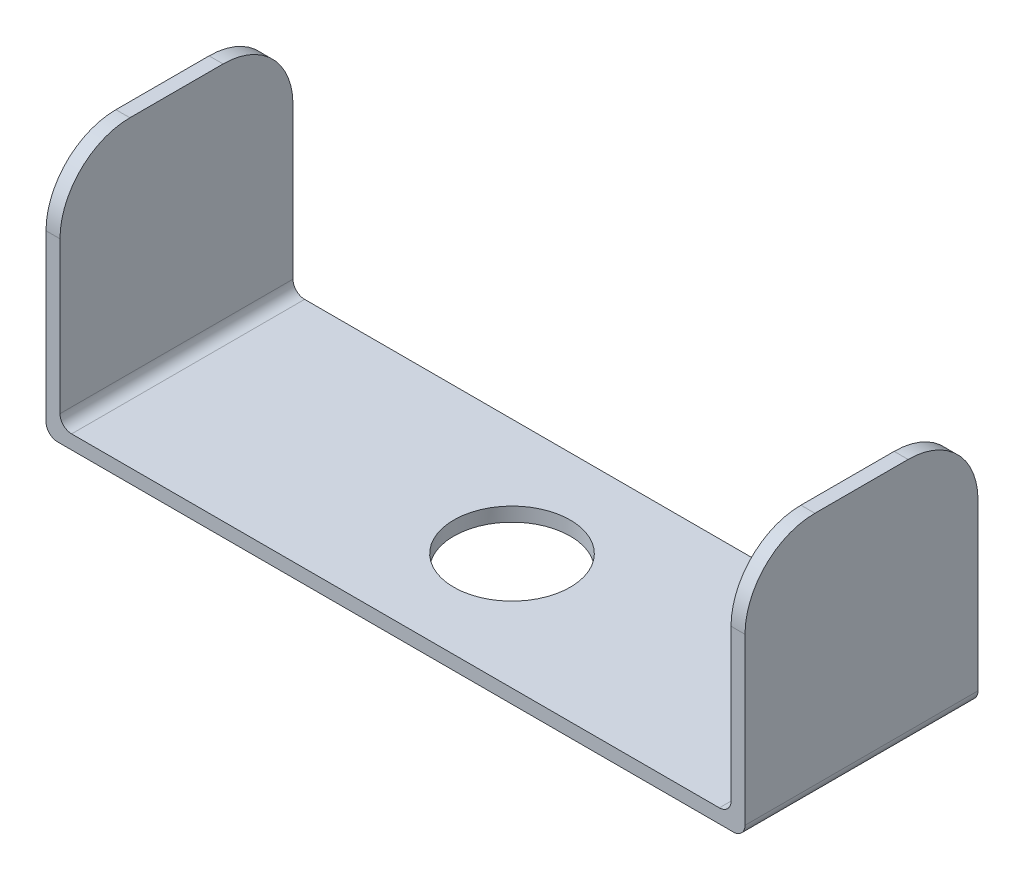
from build123d import *

# Parameters (mm, degrees)
SKETCH1_W           = 30
SKETCH1_H           = 10
BOSS_EXTRUDE1_DEPTH = 0.6
SKETCH2_W           = 0.6
SKETCH2_H           = 10
BOSS_EXTRUDE2_DEPTH = 10
FILLET1_R           = 0.5
FILLET2_R           = 3
CUT_EXTRUDE1_REACH  = 2.6
SKETCH3_R           = 2.5


with BuildPart() as part:
    # Sketch1 → Boss-Extrude1 (new body)
    with BuildSketch(Plane(origin=(0, 0, 0), x_dir=(1, 0, 0), z_dir=(0, 1, 0))):
        Rectangle(SKETCH1_W, SKETCH1_H)
    extrude(amount=BOSS_EXTRUDE1_DEPTH)

    # Sketch2 → Boss-Extrude2 (add)
    with BuildSketch(Plane(origin=(0, 0.6, 0), x_dir=(1, 0, 0), z_dir=(0, 1, 0))):
        with Locations((-14.7, 0)):
            Rectangle(SKETCH2_W, SKETCH2_H)
        with Locations((14.7, 0)):
            Rectangle(SKETCH2_W, SKETCH2_H)
    extrude(amount=BOSS_EXTRUDE2_DEPTH)

    # Fillet1
    fillet1_edges = [part.edges().sort_by_distance(p)[0] for p in [
        (-14.4, 0.6, 0),
        (14.4, 0.6, 0),
        (-15, 0, 0),
        (15, 0, 0),
    ]]
    fillet(fillet1_edges, radius=FILLET1_R)

    # Fillet2
    fillet2_edges = [part.edges().sort_by_distance(p)[0] for p in [
        (-14.7, 10.6, 5),
        (-14.7, 10.6, -5),
        (14.7, 10.6, -5),
        (14.7, 10.6, 5),
    ]]
    fillet(fillet2_edges, radius=FILLET2_R)

    # Sketch3 → Cut-Extrude1 (cut, up to next)
    with BuildSketch(Plane(origin=(0, 0.6, 0), x_dir=(1, 0, 0), z_dir=(0, 1, 0)), mode=Mode.PRIVATE) as cut_extrude1_sk1:
        Circle(SKETCH3_R)
    cut_extrude1_tool1 = extrude(cut_extrude1_sk1.sketch, amount=-CUT_EXTRUDE1_REACH, mode=Mode.PRIVATE) & part.part
    add(cut_extrude1_tool1.solids().sort_by_distance((0, 0.6, 0))[0], mode=Mode.SUBTRACT)


solid = part.part
